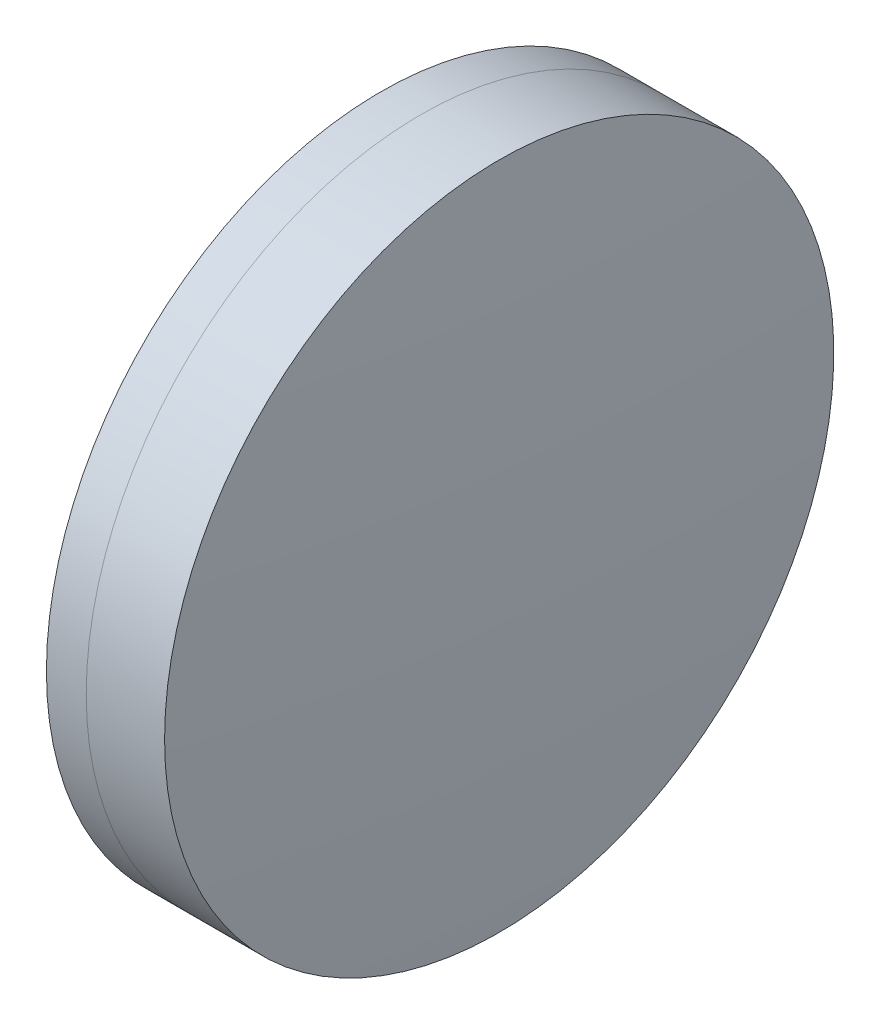
from build123d import *


with BuildPart() as part:
    # 草图1 one side → 旋转1 (revolve)
    with BuildSketch(Plane(origin=(0, 0, 0), x_dir=(1, 0, 0), z_dir=(0, 1, 0)), mode=Mode.PRIVATE) as revolve_1_sk:
        with BuildLine():
            ThreePointArc((252.846285657, 15.75), (251.913726157, 7.899528134), (251.602228187, 0))
            Line((251.602228187, 0), (256.382228187, 0))
            ThreePointArc((256.382228187, 0), (255.965693072, 7.918699791), (254.720685072, 15.75))
            Line((254.720685072, 15.75), (252.846285657, 15.75))
        make_face()
    revolve(revolve_1_sk.sketch.rotate(Axis((124.523309526, 0, 0), (1, 0, 0)), 180), axis=Axis((124.523309526, 0, 0), (1, 0, 0)))  # turned: the seam where the file's is


with BuildPart() as body_2:
    # 草图2 one side → 旋转3 (revolve)
    with BuildSketch(Plane(origin=(0, 0, 0), x_dir=(1, 0, 0), z_dir=(0, 1, 0)), mode=Mode.PRIVATE) as revolve_3_sk:
        with BuildLine():
            Line((258.408614, 15.75), (254.720685072, 15.75))
            ThreePointArc((254.720685072, 15.75), (255.965693072, 7.918699791), (256.382228187, 0))
            Line((256.382228187, 0), (258.942228187, 0))
            ThreePointArc((258.942228187, 0), (258.80878638, 7.879518451), (258.408614, 15.75))
        make_face()
    revolve(revolve_3_sk.sketch.rotate(Axis((-0.551919993, 0, 0), (1, 0, 0)), 180), axis=Axis((-0.551919993, 0, 0), (1, 0, 0)))  # turned: the seam where the file's is


solid = Compound([part.part, body_2.part])
